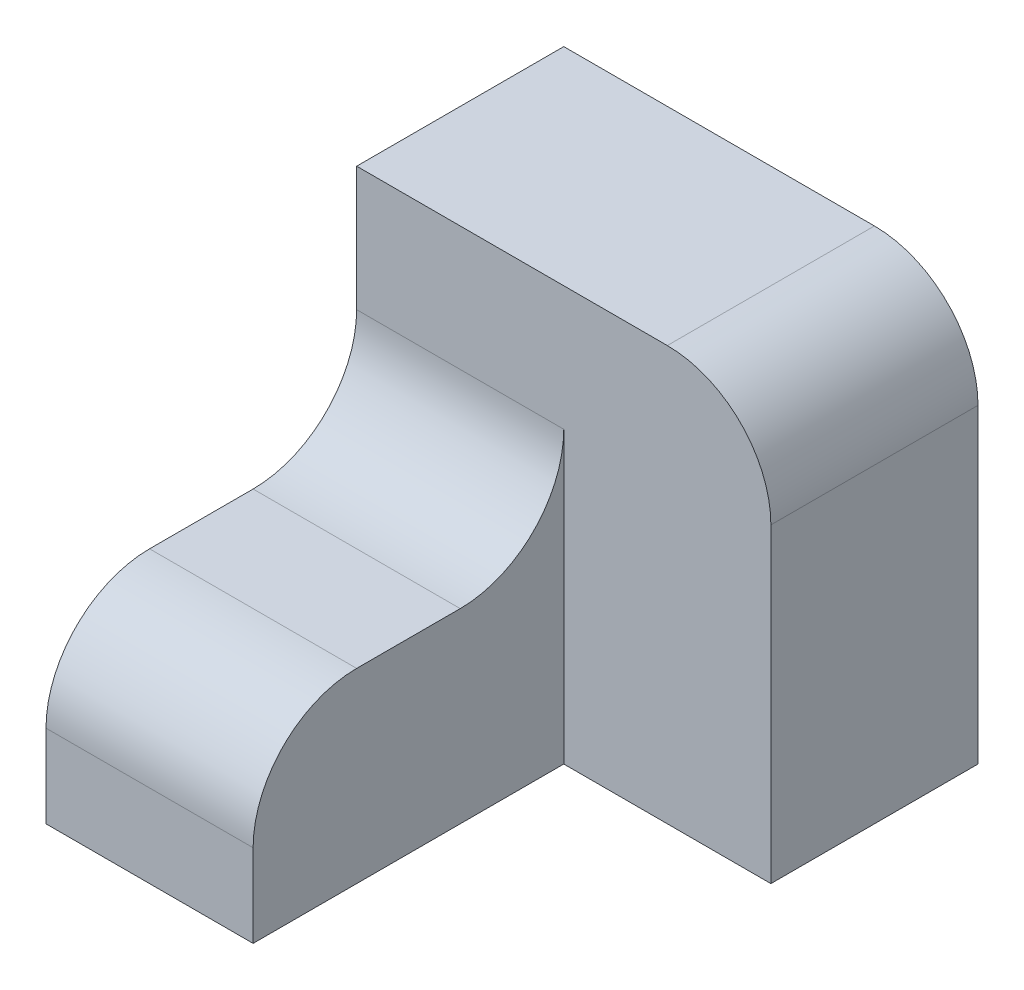
from build123d import *

# Parameters (mm, degrees)
SKETCH1_W           = 20
SKETCH1_H           = 18
BOSS_EXTRUDE1_DEPTH = 30
SKETCH2_W           = 40
SKETCH2_H           = 40
BOSS_EXTRUDE2_DEPTH = 20
FILLET1_R           = 10


with BuildPart() as part:
    # Sketch1 → Boss-Extrude1 (new body)
    with BuildSketch(Plane.XY):
        with Locations((-20, -9)):
            Rectangle(SKETCH1_W, SKETCH1_H)
    extrude(amount=BOSS_EXTRUDE1_DEPTH)

    # Sketch2 → Boss-Extrude2 (add)
    with BuildSketch(Plane.XY):
        with Locations((-10, 2)):
            Rectangle(SKETCH2_W, SKETCH2_H)
    extrude(amount=-BOSS_EXTRUDE2_DEPTH)

    # Fillet1
    fillet1_edges = [part.edges().sort_by_distance(p)[0] for p in [
        (10, 22, -10),
        (-20, 0, 30),
        (-20, 0, 0),
    ]]
    fillet(fillet1_edges, radius=FILLET1_R)


solid = part.part
